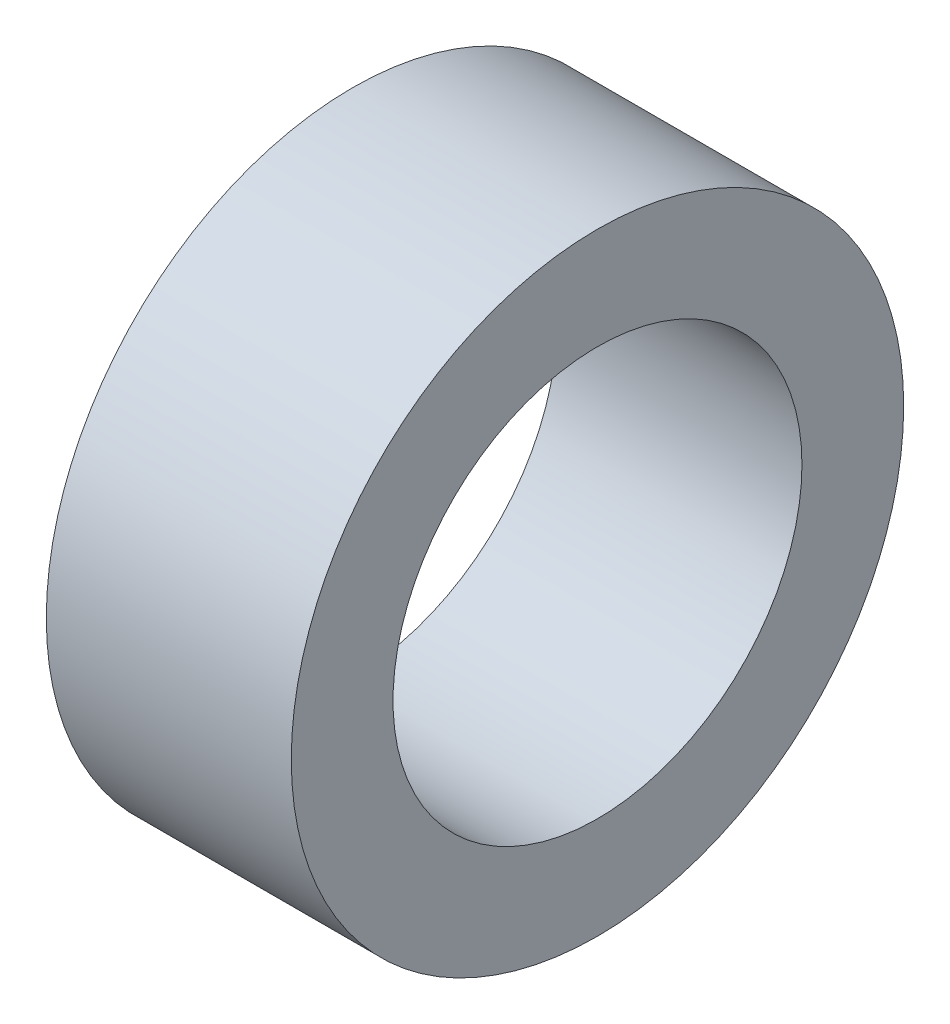
from build123d import *

# Parameters (mm, degrees)
SKETCH1_R           = 3.96875
SKETCH1_R_2         = 2.65
BOSS_EXTRUDE1_DEPTH = 3.175


with BuildPart() as part:
    # Sketch1 → Boss-Extrude1 (new body)
    with BuildSketch(Plane(origin=(0, 0, 0), x_dir=(0, 0, -1), z_dir=(1, 0, 0))):
        Circle(SKETCH1_R)
        Circle(SKETCH1_R_2, mode=Mode.SUBTRACT)
    extrude(amount=BOSS_EXTRUDE1_DEPTH)


solid = part.part
